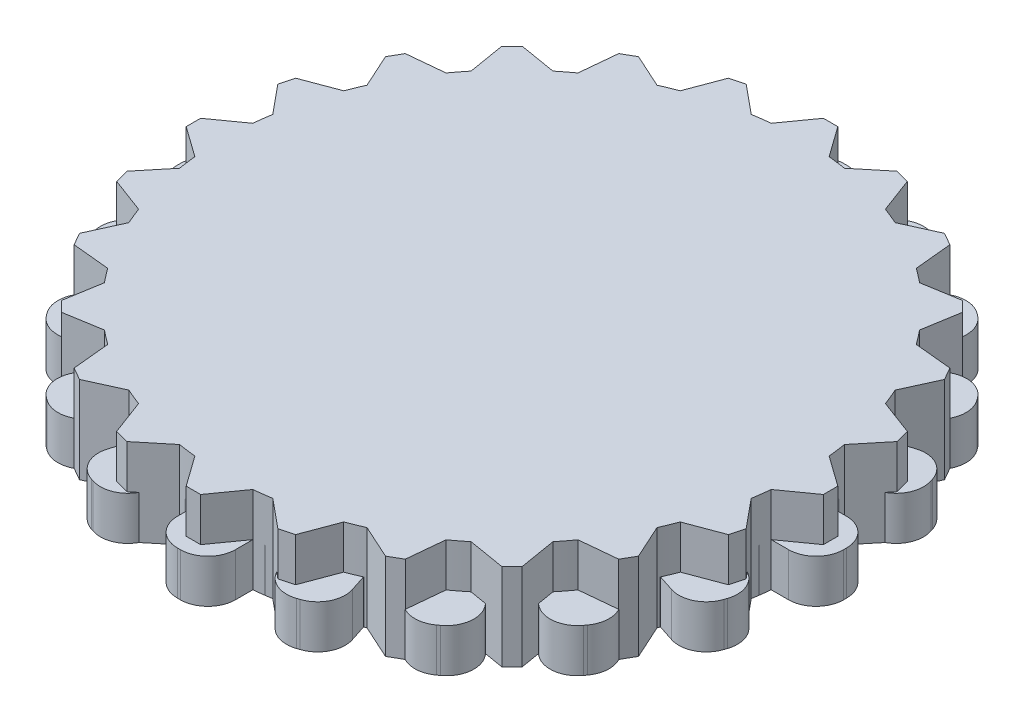
from build123d import *

# Parameters (mm, degrees)
BOSS_EXTRUDE3_DEPTH = 3
BOSS_EXTRUDE5_DEPTH = 6
BOSS_EXTRUDE6_DEPTH = 6


with BuildPart() as part:
    # Sketch2 → Boss-Extrude3 (new body)
    with BuildSketch(Plane(origin=(0, 0, 0), x_dir=(1, 0, 0), z_dir=(0, 1, 0))):
        with BuildLine():
            Line((-23, -0.1), (-23, 0.1))
            ThreePointArc((-23, 0.1), (-22.443502884, 1.443502884), (-21.1, 2))
            Line((-21.1, 2), (-19.899748742, 2))
            ThreePointArc((-19.899748742, 2), (-19.753766812, 3.128689301), (-19.543819703, 4.247247513))
            Line((-19.543819703, 4.247247513), (-20.685326483, 4.618145549))
            ThreePointArc((-20.685326483, 4.618145549), (-21.791106589, 5.56257098), (-21.905201574, 7.012285219))
            Line((-21.905201574, 7.012285219), (-21.843398175, 7.202496522))
            ThreePointArc((-21.843398175, 7.202496522), (-20.898972744, 8.308276629), (-19.449258505, 8.422371614))
            Line((-19.449258505, 8.422371614), (-18.307751725, 8.051473578))
            ThreePointArc((-18.307751725, 8.051473578), (-17.820130484, 9.079809995), (-17.274805421, 10.078744846))
            Line((-17.274805421, 10.078744846), (-18.245829086, 10.784234835))
            ThreePointArc((-18.245829086, 10.784234835), (-19.005644954, 12.02414164), (-18.666169396, 13.438159103))
            Line((-18.666169396, 13.438159103), (-18.548612345, 13.599962502))
            ThreePointArc((-18.548612345, 13.599962502), (-17.30870554, 14.35977837), (-15.894688077, 14.020302812))
            Line((-15.894688077, 14.020302812), (-14.923664412, 13.314812824))
            ThreePointArc((-14.923664412, 13.314812824), (-14.142135624, 14.142135624), (-13.314812824, 14.923664412))
            Line((-13.314812824, 14.923664412), (-14.020302812, 15.894688077))
            ThreePointArc((-14.020302812, 15.894688077), (-14.35977837, 17.30870554), (-13.599962502, 18.548612345))
            Line((-13.599962502, 18.548612345), (-13.438159103, 18.666169396))
            ThreePointArc((-13.438159103, 18.666169396), (-12.02414164, 19.005644954), (-10.784234835, 18.245829086))
            Line((-10.784234835, 18.245829086), (-10.078744846, 17.274805421))
            ThreePointArc((-10.078744846, 17.274805421), (-9.079809995, 17.820130484), (-8.051473578, 18.307751725))
            Line((-8.051473578, 18.307751725), (-8.422371614, 19.449258505))
            ThreePointArc((-8.422371614, 19.449258505), (-8.308276629, 20.898972744), (-7.202496522, 21.843398175))
            Line((-7.202496522, 21.843398175), (-7.012285219, 21.905201574))
            ThreePointArc((-7.012285219, 21.905201574), (-5.56257098, 21.791106589), (-4.618145549, 20.685326483))
            Line((-4.618145549, 20.685326483), (-4.247247513, 19.543819703))
            ThreePointArc((-4.247247513, 19.543819703), (-3.128689301, 19.753766812), (-2, 19.899748742))
            Line((-2, 19.899748742), (-2, 21.1))
            ThreePointArc((-2, 21.1), (-1.443502884, 22.443502884), (-0.1, 23))
            Line((-0.1, 23), (0.1, 23))
            ThreePointArc((0.1, 23), (1.443502884, 22.443502884), (2, 21.1))
            Line((2, 21.1), (2, 19.899748742))
            ThreePointArc((2, 19.899748742), (3.128689301, 19.753766812), (4.247247513, 19.543819703))
            Line((4.247247513, 19.543819703), (4.618145549, 20.685326483))
            ThreePointArc((4.618145549, 20.685326483), (5.56257098, 21.791106589), (7.012285219, 21.905201574))
            Line((7.012285219, 21.905201574), (7.202496522, 21.843398175))
            ThreePointArc((7.202496522, 21.843398175), (8.308276629, 20.898972744), (8.422371614, 19.449258505))
            Line((8.422371614, 19.449258505), (8.051473578, 18.307751725))
            ThreePointArc((8.051473578, 18.307751725), (9.079809995, 17.820130484), (10.078744846, 17.274805421))
            Line((10.078744846, 17.274805421), (10.784234835, 18.245829086))
            ThreePointArc((10.784234835, 18.245829086), (12.02414164, 19.005644954), (13.438159103, 18.666169396))
            Line((13.438159103, 18.666169396), (13.599962502, 18.548612345))
            ThreePointArc((13.599962502, 18.548612345), (14.35977837, 17.30870554), (14.020302812, 15.894688077))
            Line((14.020302812, 15.894688077), (13.314812824, 14.923664412))
            ThreePointArc((13.314812824, 14.923664412), (14.142135624, 14.142135624), (14.923664412, 13.314812824))
            Line((14.923664412, 13.314812824), (15.894688077, 14.020302812))
            ThreePointArc((15.894688077, 14.020302812), (17.30870554, 14.35977837), (18.548612345, 13.599962502))
            Line((18.548612345, 13.599962502), (18.666169396, 13.438159103))
            ThreePointArc((18.666169396, 13.438159103), (19.005644954, 12.02414164), (18.245829086, 10.784234835))
            Line((18.245829086, 10.784234835), (17.274805421, 10.078744846))
            ThreePointArc((17.274805421, 10.078744846), (17.820130484, 9.079809995), (18.307751725, 8.051473578))
            Line((18.307751725, 8.051473578), (19.449258505, 8.422371614))
            ThreePointArc((19.449258505, 8.422371614), (20.898972744, 8.308276629), (21.843398175, 7.202496522))
            Line((21.843398175, 7.202496522), (21.905201574, 7.012285219))
            ThreePointArc((21.905201574, 7.012285219), (21.791106589, 5.56257098), (20.685326483, 4.618145549))
            Line((20.685326483, 4.618145549), (19.543819703, 4.247247513))
            ThreePointArc((19.543819703, 4.247247513), (19.753766812, 3.128689301), (19.899748742, 2))
            Line((19.899748742, 2), (21.1, 2))
            ThreePointArc((21.1, 2), (22.443502884, 1.443502884), (23, 0.1))
            Line((23, 0.1), (23, -0.1))
            ThreePointArc((23, -0.1), (22.443502884, -1.443502884), (21.1, -2))
            Line((21.1, -2), (19.899748742, -2))
            ThreePointArc((19.899748742, -2), (19.753766812, -3.128689301), (19.543819703, -4.247247513))
            Line((19.543819703, -4.247247513), (20.685326483, -4.618145549))
            ThreePointArc((20.685326483, -4.618145549), (21.791106589, -5.56257098), (21.905201574, -7.012285219))
            Line((21.905201574, -7.012285219), (21.843398175, -7.202496522))
            ThreePointArc((21.843398175, -7.202496522), (20.898972744, -8.308276629), (19.449258505, -8.422371614))
            Line((19.449258505, -8.422371614), (18.307751725, -8.051473578))
            ThreePointArc((18.307751725, -8.051473578), (17.820130484, -9.079809995), (17.274805421, -10.078744846))
            Line((17.274805421, -10.078744846), (18.245829086, -10.784234835))
            ThreePointArc((18.245829086, -10.784234835), (19.005644954, -12.02414164), (18.666169396, -13.438159103))
            Line((18.666169396, -13.438159103), (18.548612345, -13.599962502))
            ThreePointArc((18.548612345, -13.599962502), (17.30870554, -14.35977837), (15.894688077, -14.020302812))
            Line((15.894688077, -14.020302812), (14.923664412, -13.314812824))
            ThreePointArc((14.923664412, -13.314812824), (14.142135624, -14.142135624), (13.314812824, -14.923664412))
            Line((13.314812824, -14.923664412), (14.020302812, -15.894688077))
            ThreePointArc((14.020302812, -15.894688077), (14.35977837, -17.30870554), (13.599962502, -18.548612345))
            Line((13.599962502, -18.548612345), (13.438159103, -18.666169396))
            ThreePointArc((13.438159103, -18.666169396), (12.02414164, -19.005644954), (10.784234835, -18.245829086))
            Line((10.784234835, -18.245829086), (10.078744846, -17.274805421))
            ThreePointArc((10.078744846, -17.274805421), (9.079809995, -17.820130484), (8.051473578, -18.307751725))
            Line((8.051473578, -18.307751725), (8.422371614, -19.449258505))
            ThreePointArc((8.422371614, -19.449258505), (8.308276629, -20.898972744), (7.202496522, -21.843398175))
            Line((7.202496522, -21.843398175), (7.012285219, -21.905201574))
            ThreePointArc((7.012285219, -21.905201574), (5.56257098, -21.791106589), (4.618145549, -20.685326483))
            Line((4.618145549, -20.685326483), (4.247247513, -19.543819703))
            ThreePointArc((4.247247513, -19.543819703), (3.128689301, -19.753766812), (2, -19.899748742))
            Line((2, -19.899748742), (2, -21.1))
            ThreePointArc((2, -21.1), (1.443502884, -22.443502884), (0.1, -23))
            Line((0.1, -23), (-0.1, -23))
            ThreePointArc((-0.1, -23), (-1.443502884, -22.443502884), (-2, -21.1))
            Line((-2, -21.1), (-2, -19.899748742))
            ThreePointArc((-2, -19.899748742), (-3.128689301, -19.753766812), (-4.247247513, -19.543819703))
            Line((-4.247247513, -19.543819703), (-4.618145549, -20.685326483))
            ThreePointArc((-4.618145549, -20.685326483), (-5.56257098, -21.791106589), (-7.012285219, -21.905201574))
            Line((-7.012285219, -21.905201574), (-7.202496522, -21.843398175))
            ThreePointArc((-7.202496522, -21.843398175), (-8.308276629, -20.898972744), (-8.422371614, -19.449258505))
            Line((-8.422371614, -19.449258505), (-8.051473578, -18.307751725))
            ThreePointArc((-8.051473578, -18.307751725), (-9.079809995, -17.820130484), (-10.078744846, -17.274805421))
            Line((-10.078744846, -17.274805421), (-10.784234835, -18.245829086))
            ThreePointArc((-10.784234835, -18.245829086), (-12.02414164, -19.005644954), (-13.438159103, -18.666169396))
            Line((-13.438159103, -18.666169396), (-13.599962502, -18.548612345))
            ThreePointArc((-13.599962502, -18.548612345), (-14.35977837, -17.30870554), (-14.020302812, -15.894688077))
            Line((-14.020302812, -15.894688077), (-13.314812824, -14.923664412))
            ThreePointArc((-13.314812824, -14.923664412), (-14.142135624, -14.142135624), (-14.923664412, -13.314812824))
            Line((-14.923664412, -13.314812824), (-15.894688077, -14.020302812))
            ThreePointArc((-15.894688077, -14.020302812), (-17.30870554, -14.35977837), (-18.548612345, -13.599962502))
            Line((-18.548612345, -13.599962502), (-18.666169396, -13.438159103))
            ThreePointArc((-18.666169396, -13.438159103), (-19.005644954, -12.02414164), (-18.245829086, -10.784234835))
            Line((-18.245829086, -10.784234835), (-17.274805421, -10.078744846))
            ThreePointArc((-17.274805421, -10.078744846), (-17.820130484, -9.079809995), (-18.307751725, -8.051473578))
            Line((-18.307751725, -8.051473578), (-19.449258505, -8.422371614))
            ThreePointArc((-19.449258505, -8.422371614), (-20.898972744, -8.308276629), (-21.843398175, -7.202496522))
            Line((-21.843398175, -7.202496522), (-21.905201574, -7.012285219))
            ThreePointArc((-21.905201574, -7.012285219), (-21.791106589, -5.56257098), (-20.685326483, -4.618145549))
            Line((-20.685326483, -4.618145549), (-19.543819703, -4.247247513))
            ThreePointArc((-19.543819703, -4.247247513), (-19.753766812, -3.128689301), (-19.899748742, -2))
            Line((-19.899748742, -2), (-21.1, -2))
            ThreePointArc((-21.1, -2), (-22.443502884, -1.443502884), (-23, -0.1))
        make_face()
    extrude(amount=BOSS_EXTRUDE3_DEPTH)


with BuildPart() as body_2:
    # Sketch3 → Boss-Extrude5 (new body)
    with BuildSketch(Plane(origin=(0, 0, 0), x_dir=(1, 0, 0), z_dir=(0, 1, 0))):
        with BuildLine():
            Line((-22, 0.5), (-22, 0))
            Line((-22, 0), (22, 0))
            Line((22, 0), (22, 0.5))
            Line((22, 0.5), (19.899748742, 2))
            ThreePointArc((19.899748742, 2), (19.828897227, 2.610523844), (19.739319337, 3.218582315))
            Line((19.739319337, 3.218582315), (21.379777701, 5.211056079))
            Line((21.379777701, 5.211056079), (21.120958656, 6.176981905))
            Line((21.120958656, 6.176981905), (18.704043156, 7.08228562))
            ThreePointArc((18.704043156, 7.08228562), (18.47759065, 7.653668647), (18.23368794, 8.217823563))
            Line((18.23368794, 8.217823563), (19.302558883, 10.566987298))
            Line((19.302558883, 10.566987298), (18.802558883, 11.433012702))
            Line((18.802558883, 11.433012702), (16.23368794, 11.681925179))
            ThreePointArc((16.23368794, 11.681925179), (15.867066806, 12.17522858), (15.485460842, 12.657033717))
            Line((15.485460842, 12.657033717), (15.909902577, 15.202795796))
            Line((15.909902577, 15.202795796), (15.202795796, 15.909902577))
            Line((15.202795796, 15.909902577), (12.657033717, 15.485460842))
            ThreePointArc((12.657033717, 15.485460842), (12.17522858, 15.867066806), (11.681925179, 16.23368794))
            Line((11.681925179, 16.23368794), (11.433012702, 18.802558883))
            Line((11.433012702, 18.802558883), (10.566987298, 19.302558883))
            Line((10.566987298, 19.302558883), (8.217823563, 18.23368794))
            ThreePointArc((8.217823563, 18.23368794), (7.653668647, 18.47759065), (7.08228562, 18.704043156))
            Line((7.08228562, 18.704043156), (6.176981905, 21.120958656))
            Line((6.176981905, 21.120958656), (5.211056079, 21.379777701))
            Line((5.211056079, 21.379777701), (3.218582315, 19.739319337))
            ThreePointArc((3.218582315, 19.739319337), (2.610523844, 19.828897227), (2, 19.899748742))
            Line((2, 19.899748742), (0.5, 22))
            Line((0.5, 22), (-0.5, 22))
            Line((-0.5, 22), (-2, 19.899748742))
            ThreePointArc((-2, 19.899748742), (-2.610523844, 19.828897227), (-3.218582315, 19.739319337))
            Line((-3.218582315, 19.739319337), (-5.211056079, 21.379777701))
            Line((-5.211056079, 21.379777701), (-6.176981905, 21.120958656))
            Line((-6.176981905, 21.120958656), (-7.08228562, 18.704043156))
            ThreePointArc((-7.08228562, 18.704043156), (-7.653668647, 18.47759065), (-8.217823563, 18.23368794))
            Line((-8.217823563, 18.23368794), (-10.566987298, 19.302558883))
            Line((-10.566987298, 19.302558883), (-11.433012702, 18.802558883))
            Line((-11.433012702, 18.802558883), (-11.681925179, 16.23368794))
            ThreePointArc((-11.681925179, 16.23368794), (-12.17522858, 15.867066806), (-12.657033717, 15.485460842))
            Line((-12.657033717, 15.485460842), (-15.202795796, 15.909902577))
            Line((-15.202795796, 15.909902577), (-15.909902577, 15.202795796))
            Line((-15.909902577, 15.202795796), (-15.485460842, 12.657033717))
            ThreePointArc((-15.485460842, 12.657033717), (-15.867066806, 12.17522858), (-16.23368794, 11.681925179))
            Line((-16.23368794, 11.681925179), (-18.802558883, 11.433012702))
            Line((-18.802558883, 11.433012702), (-19.302558883, 10.566987298))
            Line((-19.302558883, 10.566987298), (-18.23368794, 8.217823563))
            ThreePointArc((-18.23368794, 8.217823563), (-18.47759065, 7.653668647), (-18.704043156, 7.08228562))
            Line((-18.704043156, 7.08228562), (-21.120958656, 6.176981905))
            Line((-21.120958656, 6.176981905), (-21.379777701, 5.211056079))
            Line((-21.379777701, 5.211056079), (-19.739319337, 3.218582315))
            ThreePointArc((-19.739319337, 3.218582315), (-19.828897227, 2.610523844), (-19.899748742, 2))
            Line((-19.899748742, 2), (-22, 0.5))
        make_face()
        with BuildLine():
            Line((22, 0), (-22, 0))
            Line((-22, 0), (-22, -0.5))
            Line((-22, -0.5), (-19.899748742, -2))
            ThreePointArc((-19.899748742, -2), (-19.828897227, -2.610523844), (-19.739319337, -3.218582315))
            Line((-19.739319337, -3.218582315), (-21.379777701, -5.211056079))
            Line((-21.379777701, -5.211056079), (-21.120958656, -6.176981905))
            Line((-21.120958656, -6.176981905), (-18.704043156, -7.08228562))
            ThreePointArc((-18.704043156, -7.08228562), (-18.47759065, -7.653668647), (-18.23368794, -8.217823563))
            Line((-18.23368794, -8.217823563), (-19.302558883, -10.566987298))
            Line((-19.302558883, -10.566987298), (-18.802558883, -11.433012702))
            Line((-18.802558883, -11.433012702), (-16.23368794, -11.681925179))
            ThreePointArc((-16.23368794, -11.681925179), (-15.867066806, -12.17522858), (-15.485460842, -12.657033717))
            Line((-15.485460842, -12.657033717), (-15.909902577, -15.202795796))
            Line((-15.909902577, -15.202795796), (-15.202795796, -15.909902577))
            Line((-15.202795796, -15.909902577), (-12.657033717, -15.485460842))
            ThreePointArc((-12.657033717, -15.485460842), (-12.17522858, -15.867066806), (-11.681925179, -16.23368794))
            Line((-11.681925179, -16.23368794), (-11.433012702, -18.802558883))
            Line((-11.433012702, -18.802558883), (-10.566987298, -19.302558883))
            Line((-10.566987298, -19.302558883), (-8.217823563, -18.23368794))
            ThreePointArc((-8.217823563, -18.23368794), (-7.653668647, -18.47759065), (-7.08228562, -18.704043156))
            Line((-7.08228562, -18.704043156), (-6.176981905, -21.120958656))
            Line((-6.176981905, -21.120958656), (-5.211056079, -21.379777701))
            Line((-5.211056079, -21.379777701), (-3.218582315, -19.739319337))
            ThreePointArc((-3.218582315, -19.739319337), (-2.610523844, -19.828897227), (-2, -19.899748742))
            Line((-2, -19.899748742), (-0.5, -22))
            Line((-0.5, -22), (0.5, -22))
            Line((0.5, -22), (2, -19.899748742))
            ThreePointArc((2, -19.899748742), (2.610523844, -19.828897227), (3.218582315, -19.739319337))
            Line((3.218582315, -19.739319337), (5.211056079, -21.379777701))
            Line((5.211056079, -21.379777701), (6.176981905, -21.120958656))
            Line((6.176981905, -21.120958656), (7.08228562, -18.704043156))
            ThreePointArc((7.08228562, -18.704043156), (7.653668647, -18.47759065), (8.217823563, -18.23368794))
            Line((8.217823563, -18.23368794), (10.566987298, -19.302558883))
            Line((10.566987298, -19.302558883), (11.433012702, -18.802558883))
            Line((11.433012702, -18.802558883), (11.681925179, -16.23368794))
            ThreePointArc((11.681925179, -16.23368794), (12.17522858, -15.867066806), (12.657033717, -15.485460842))
            Line((12.657033717, -15.485460842), (15.202795796, -15.909902577))
            Line((15.202795796, -15.909902577), (15.909902577, -15.202795796))
            Line((15.909902577, -15.202795796), (15.485460842, -12.657033717))
            ThreePointArc((15.485460842, -12.657033717), (15.867066806, -12.17522858), (16.23368794, -11.681925179))
            Line((16.23368794, -11.681925179), (18.802558883, -11.433012702))
            Line((18.802558883, -11.433012702), (19.302558883, -10.566987298))
            Line((19.302558883, -10.566987298), (18.23368794, -8.217823563))
            ThreePointArc((18.23368794, -8.217823563), (18.47759065, -7.653668647), (18.704043156, -7.08228562))
            Line((18.704043156, -7.08228562), (21.120958656, -6.176981905))
            Line((21.120958656, -6.176981905), (21.379777701, -5.211056079))
            Line((21.379777701, -5.211056079), (19.739319337, -3.218582315))
            ThreePointArc((19.739319337, -3.218582315), (19.828897227, -2.610523844), (19.899748742, -2))
            Line((19.899748742, -2), (22, -0.5))
            Line((22, -0.5), (22, 0))
        make_face()
    extrude(amount=BOSS_EXTRUDE5_DEPTH)


with BuildPart() as body_3:
    # Sketch1 → Boss-Extrude6 (new body)
    with BuildSketch(Plane(origin=(0, 0, 0), x_dir=(1, 0, 0), z_dir=(0, 1, 0))):
        with BuildLine():
            Line((-1.142396869, 14.033495942), (-0.142396869, 14.033495942))
            Line((-0.142396869, 14.033495942), (0.857603131, 11.733495942))
            ThreePointArc((0.857603131, 11.733495942), (1.557565014, 11.5772652), (2.241865158, 11.36258405))
            Line((2.241865158, 11.36258405), (4.257890562, 12.854442478))
            Line((4.257890562, 12.854442478), (5.123915966, 12.354442478))
            Line((5.123915966, 12.354442478), (4.839941369, 9.86258405))
            ThreePointArc((4.839941369, 9.86258405), (5.368010771, 9.377303317), (5.853291504, 8.849233915))
            Line((5.853291504, 8.849233915), (8.345149933, 9.133208511))
            Line((8.345149933, 9.133208511), (8.845149933, 8.267183107))
            Line((8.845149933, 8.267183107), (7.353291504, 6.251157704))
            ThreePointArc((7.353291504, 6.251157704), (7.567972654, 5.56685756), (7.724203396, 4.866895677))
            Line((7.724203396, 4.866895677), (10.024203396, 3.866895677))
            Line((10.024203396, 3.866895677), (10.024203396, 2.866895677))
            Line((10.024203396, 2.866895677), (7.724203396, 1.866895677))
            ThreePointArc((7.724203396, 1.866895677), (7.567972654, 1.166933793), (7.353291504, 0.48263365))
            Line((7.353291504, 0.48263365), (8.845149933, -1.533391754))
            Line((8.845149933, -1.533391754), (8.345149933, -2.399417158))
            Line((8.345149933, -2.399417158), (5.853291504, -2.115442562))
            ThreePointArc((5.853291504, -2.115442562), (5.368010771, -2.643511964), (4.839941369, -3.128792697))
            Line((4.839941369, -3.128792697), (5.123915966, -5.620651125))
            Line((5.123915966, -5.620651125), (4.257890562, -6.120651125))
            Line((4.257890562, -6.120651125), (2.241865158, -4.628792697))
            ThreePointArc((2.241865158, -4.628792697), (1.557565014, -4.843473847), (0.857603131, -4.999704589))
            Line((0.857603131, -4.999704589), (-0.142396869, -7.299704589))
            Line((-0.142396869, -7.299704589), (-1.142396869, -7.299704589))
            Line((-1.142396869, -7.299704589), (-2.142396869, -4.999704589))
            ThreePointArc((-2.142396869, -4.999704589), (-2.842358752, -4.843473847), (-3.526658896, -4.628792697))
            Line((-3.526658896, -4.628792697), (-5.5426843, -6.120651125))
            Line((-5.5426843, -6.120651125), (-6.408709704, -5.620651125))
            Line((-6.408709704, -5.620651125), (-6.124735107, -3.128792697))
            ThreePointArc((-6.124735107, -3.128792697), (-6.652804509, -2.643511964), (-7.138085242, -2.115442562))
            Line((-7.138085242, -2.115442562), (-9.629943671, -2.399417158))
            Line((-9.629943671, -2.399417158), (-10.129943671, -1.533391754))
            Line((-10.129943671, -1.533391754), (-8.638085242, 0.48263365))
            ThreePointArc((-8.638085242, 0.48263365), (-8.852766392, 1.166933793), (-9.008997134, 1.866895677))
            Line((-9.008997134, 1.866895677), (-11.308997134, 2.866895677))
            Line((-11.308997134, 2.866895677), (-11.308997134, 3.866895677))
            Line((-11.308997134, 3.866895677), (-9.008997134, 4.866895677))
            ThreePointArc((-9.008997134, 4.866895677), (-8.852766392, 5.56685756), (-8.638085242, 6.251157704))
            Line((-8.638085242, 6.251157704), (-10.129943671, 8.267183107))
            Line((-10.129943671, 8.267183107), (-9.629943671, 9.133208511))
            Line((-9.629943671, 9.133208511), (-7.138085242, 8.849233915))
            ThreePointArc((-7.138085242, 8.849233915), (-6.652804509, 9.377303317), (-6.124735107, 9.86258405))
            Line((-6.124735107, 9.86258405), (-6.408709704, 12.354442478))
            Line((-6.408709704, 12.354442478), (-5.5426843, 12.854442478))
            Line((-5.5426843, 12.854442478), (-3.526658896, 11.36258405))
            ThreePointArc((-3.526658896, 11.36258405), (-2.842358752, 11.5772652), (-2.142396869, 11.733495942))
            Line((-2.142396869, 11.733495942), (-1.142396869, 14.033495942))
        make_face()
        with BuildLine():
            Line((-2.642396869, 4.866895677), (1.357603131, 4.866895677))
            ThreePointArc((1.357603131, 4.866895677), (1.857603131, 3.366895677), (1.357603131, 1.866895677))
            Line((1.357603131, 1.866895677), (-2.642396869, 1.866895677))
            ThreePointArc((-2.642396869, 1.866895677), (-3.142396869, 3.366895677), (-2.642396869, 4.866895677))
        make_face(mode=Mode.SUBTRACT)
    extrude(amount=BOSS_EXTRUDE6_DEPTH)


solid = Compound([part.part, body_2.part, body_3.part])
